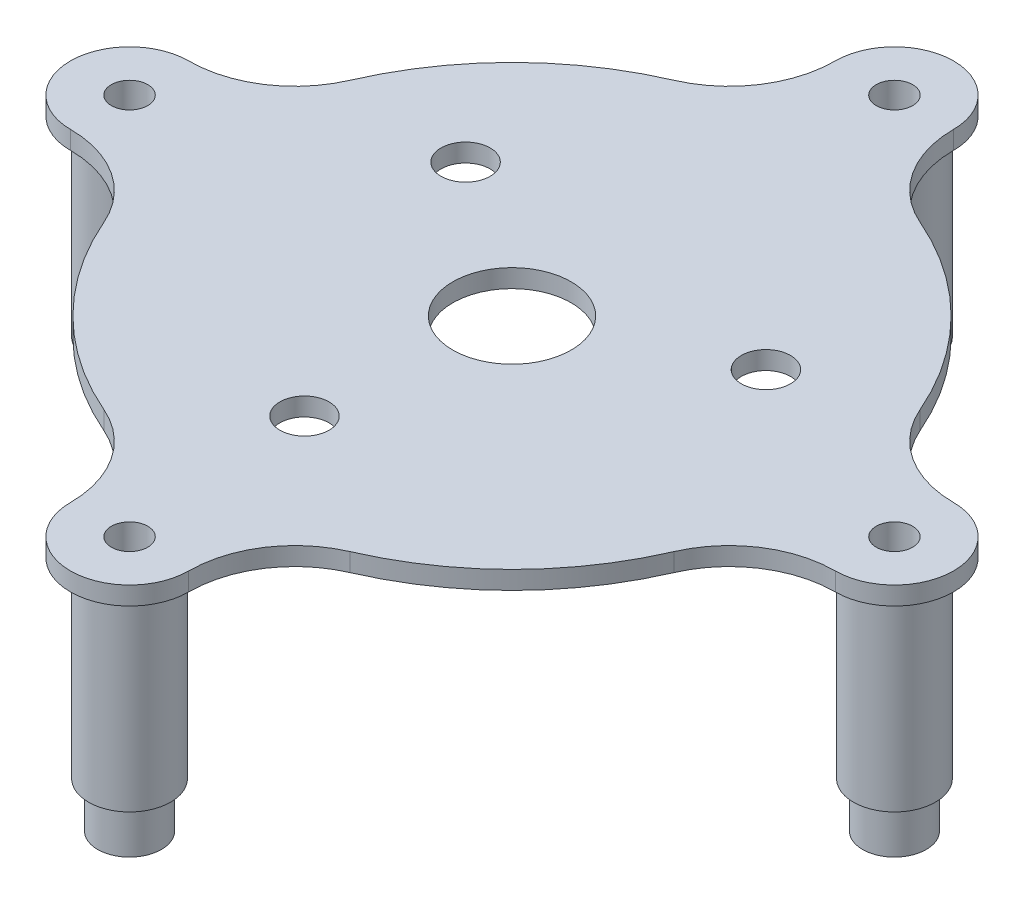
from build123d import *

# Parameters (mm, degrees)
SKETCH1_R           = 2
SKETCH1_R_2         = 2.7
SKETCH1_R_3         = 6.5
BOSS_EXTRUDE1_DEPTH = 2
SKETCH1_3_R         = 4.5
SKETCH1_3_R_2       = 3.5
SKETCH1_3_R_3       = 2
BOSS_EXTRUDE2_DEPTH = 26
CUT_EXTRUDE1_START  = -26
SKETCH1_4_R         = 4.5
SKETCH1_4_R_2       = 3.5
CUT_EXTRUDE1_DEPTH  = 5


with BuildPart() as part:
    # Sketch1 → Boss-Extrude1 (new body)
    with BuildSketch(Plane(origin=(0, 0, 0), x_dir=(1, 0, 0), z_dir=(0, 1, 0))):
        with BuildLine():
            ThreePointArc((31.3004561, 13.531128848), (24.112341238, 24.112341238), (13.531128848, 31.3004561))
            ThreePointArc((13.531128848, 31.3004561), (8.415102647, 35.598496025), (6.5, 42))
            ThreePointArc((6.5, 42), (0, 48.5), (-6.5, 42))
            ThreePointArc((-6.5, 42), (-8.415102647, 35.598496025), (-13.531128848, 31.3004561))
            ThreePointArc((-13.531128848, 31.3004561), (-24.112341238, 24.112341238), (-31.3004561, 13.531128848))
            ThreePointArc((-31.3004561, 13.531128848), (-35.598496025, 8.415102647), (-42, 6.5))
            ThreePointArc((-42, 6.5), (-48.5, 0), (-42, -6.5))
            ThreePointArc((-42, -6.5), (-35.598496025, -8.415102647), (-31.3004561, -13.531128848))
            ThreePointArc((-31.3004561, -13.531128848), (-24.112341238, -24.112341238), (-13.531128848, -31.3004561))
            ThreePointArc((-13.531128848, -31.3004561), (-8.415102647, -35.598496025), (-6.5, -42))
            ThreePointArc((-6.5, -42), (0, -48.5), (6.5, -42))
            ThreePointArc((6.5, -42), (8.415102647, -35.598496025), (13.531128848, -31.3004561))
            ThreePointArc((13.531128848, -31.3004561), (24.112341238, -24.112341238), (31.3004561, -13.531128848))
            ThreePointArc((31.3004561, -13.531128848), (35.598496025, -8.415102647), (42, -6.5))
            ThreePointArc((42, -6.5), (48.5, 0), (42, 6.5))
            ThreePointArc((42, 6.5), (35.598496025, 8.415102647), (31.3004561, 13.531128848))
        make_face()
        with Locations(Location((-42, 0, 0), (0, 0, 270))):
            Circle(SKETCH1_R, mode=Mode.SUBTRACT)
        with Locations(Location((-1.872696433, -20.916333524, 0), (0, 0, 270))):
            Circle(SKETCH1_R_2, mode=Mode.SUBTRACT)
        with Locations(Location((0, -42, 0), (0, 0, 270))):
            Circle(SKETCH1_R, mode=Mode.SUBTRACT)
        with Locations(Location((0, 0, 0), (0, 0, 270))):
            Circle(SKETCH1_R_3, mode=Mode.SUBTRACT)
        with Locations(Location((42, 0, 0), (0, 0, 270))):
            Circle(SKETCH1_R, mode=Mode.SUBTRACT)
        with Locations(Location((-17.177727969, 12.079969447, 0), (0, 0, 270))):
            Circle(SKETCH1_R_2, mode=Mode.SUBTRACT)
        with Locations(Location((19.050424402, 8.836364077, 0), (0, 0, 270))):
            Circle(SKETCH1_R_2, mode=Mode.SUBTRACT)
        with Locations(Location((0, 42, 0), (0, 0, 270))):
            Circle(SKETCH1_R, mode=Mode.SUBTRACT)
    extrude(amount=BOSS_EXTRUDE1_DEPTH)

    # Sketch1_3 → Boss-Extrude2 (add)
    with BuildSketch(Plane(origin=(0, 0, 0), x_dir=(1, 0, 0), z_dir=(0, 1, 0))):
        with BuildLine():
            ThreePointArc((46.5, 0), (42, 4.5), (37.5, 0))
            Line((37.5, 0), (38.5, 0))
            ThreePointArc((38.5, 0), (42, 3.5), (45.5, 0))
            Line((45.5, 0), (46.5, 0))
        make_face()
        with BuildLine():
            Line((38.5, 0), (37.5, 0))
            ThreePointArc((37.5, 0), (42, -4.5), (46.5, 0))
            Line((46.5, 0), (45.5, 0))
            ThreePointArc((45.5, 0), (42, -3.5), (38.5, 0))
        make_face()
        with BuildLine():
            ThreePointArc((45.5, 0), (42, 3.5), (38.5, 0))
            Line((38.5, 0), (40, 0))
            ThreePointArc((40, 0), (42, 2), (44, 0))
            Line((44, 0), (45.5, 0))
        make_face()
        with BuildLine():
            Line((40, 0), (38.5, 0))
            ThreePointArc((38.5, 0), (42, -3.5), (45.5, 0))
            Line((45.5, 0), (44, 0))
            ThreePointArc((44, 0), (42, -2), (40, 0))
        make_face()
        with Locations(Location((0, -42, 0), (0, 0, 270))):
            Circle(SKETCH1_3_R)
        with Locations((0, -42)):
            Circle(SKETCH1_3_R_2, mode=Mode.SUBTRACT)
        with Locations((0, -42)):
            Circle(SKETCH1_3_R_2)
        with Locations(Location((0, -42, 0), (0, 0, 270))):
            Circle(SKETCH1_3_R_3, mode=Mode.SUBTRACT)
        with Locations(Location((-42, 0, 0), (0, 0, 270))):
            Circle(SKETCH1_3_R)
        with Locations((-42, 0)):
            Circle(SKETCH1_3_R_2, mode=Mode.SUBTRACT)
        with Locations((-42, 0)):
            Circle(SKETCH1_3_R_2)
        with Locations(Location((-42, 0, 0), (0, 0, 270))):
            Circle(SKETCH1_3_R_3, mode=Mode.SUBTRACT)
        with Locations(Location((0, 42, 0), (0, 0, 270))):
            Circle(SKETCH1_3_R)
        with Locations((0, 42)):
            Circle(SKETCH1_3_R_2, mode=Mode.SUBTRACT)
        with Locations((0, 42)):
            Circle(SKETCH1_3_R_2)
        with Locations(Location((0, 42, 0), (0, 0, 270))):
            Circle(SKETCH1_3_R_3, mode=Mode.SUBTRACT)
    extrude(amount=-BOSS_EXTRUDE2_DEPTH)

    # Sketch1_4 → Cut-Extrude1 (cut)
    with BuildSketch(Plane(origin=(0, 0, 0), x_dir=(1, 0, 0), z_dir=(0, 1, 0)).offset(CUT_EXTRUDE1_START)):
        with Locations(Location((0, -42, 0), (0, 0, 270))):
            Circle(SKETCH1_4_R)
        with Locations(Location((0, -42, 0), (0, 0, 270))):
            Circle(SKETCH1_4_R_2, mode=Mode.SUBTRACT)
        with BuildLine():
            ThreePointArc((46.5, 0), (42, 4.5), (37.5, 0))
            Line((37.5, 0), (38.5, 0))
            ThreePointArc((38.5, 0), (42, 3.5), (45.5, 0))
            Line((45.5, 0), (46.5, 0))
        make_face()
        with BuildLine():
            Line((38.5, 0), (37.5, 0))
            ThreePointArc((37.5, 0), (42, -4.5), (46.5, 0))
            Line((46.5, 0), (45.5, 0))
            ThreePointArc((45.5, 0), (42, -3.5), (38.5, 0))
        make_face()
        with Locations(Location((0, 42, 0), (0, 0, 270))):
            Circle(SKETCH1_4_R)
        with Locations(Location((0, 42, 0), (0, 0, 270))):
            Circle(SKETCH1_4_R_2, mode=Mode.SUBTRACT)
        with Locations(Location((-42, 0, 0), (0, 0, 270))):
            Circle(SKETCH1_4_R)
        with Locations(Location((-42, 0, 0), (0, 0, 270))):
            Circle(SKETCH1_4_R_2, mode=Mode.SUBTRACT)
    extrude(amount=CUT_EXTRUDE1_DEPTH, mode=Mode.SUBTRACT)


solid = part.part
